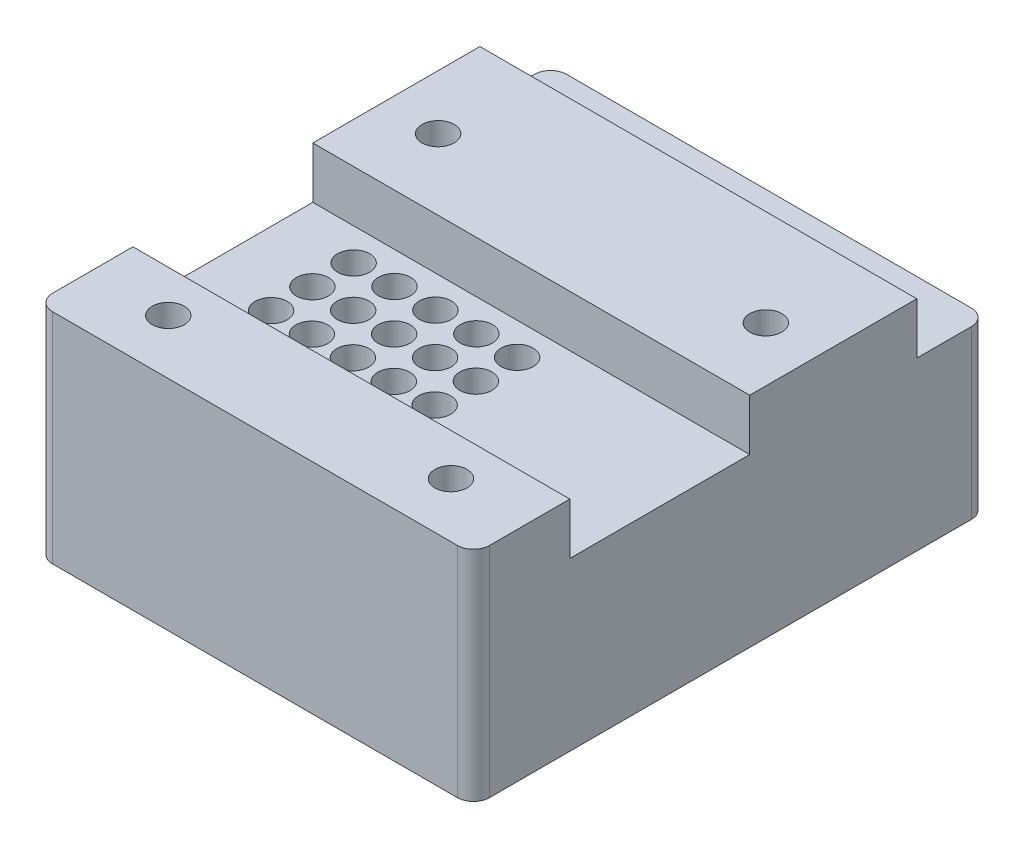
from build123d import *

# Parameters (mm, degrees)
SKETCH1_W            = 68
SKETCH1_H            = 70
BOSS_EXTRUDE2_DEPTH  = 4
SKETCH2_W            = 13.5
SKETCH2_H            = 5
BOSS_EXTRUDE4_DEPTH  = 22
SKETCH3_R            = 2
CUT_EXTRUDE1_DEPTH   = 10
SKETCH4_W            = 5
SKETCH4_H            = 25.69
BOSS_EXTRUDE5_DEPTH  = 15
SKETCH5_R            = 1.3
CUT_EXTRUDE2_DEPTH   = 6
SKETCH6_W            = 68
SKETCH6_H            = 4
BOSS_EXTRUDE6_DEPTH  = 10
BOSS_EXTRUDE7_DEPTH  = 22
SKETCH8_W            = 3
SKETCH8_H            = 26
BOSS_EXTRUDE8_DEPTH  = 22
BOSS_EXTRUDE9_DEPTH  = 22
SKETCH12_W           = 3
SKETCH12_H           = 1
CUT_EXTRUDE5_DEPTH   = 7
SKETCH13_W           = 68
SKETCH13_H           = 26
SKETCH13_H_2         = 15
BOSS_EXTRUDE12_DEPTH = 8
SKETCH19_W           = 6
SKETCH19_H           = 61
CUT_EXTRUDE8_DEPTH   = 22
SKETCH20_W           = 3
SKETCH20_H           = 3
BOSS_EXTRUDE13_DEPTH = 22
SKETCH21_R           = 2.5
CUT_EXTRUDE9_DEPTH   = 22
SKETCH22_R           = 5.004310541
SKETCH22_R_2         = 5.00398022
SKETCH22_R_3         = 4.995044229
SKETCH22_R_4         = 4.998284189
CUT_EXTRUDE10_DEPTH  = 6
SKETCH24_W           = 3
SKETCH24_H           = 3
BOSS_EXTRUDE14_DEPTH = 22
SKETCH26_R           = 1.2
CUT_EXTRUDE11_DEPTH  = 5
SKETCH27_R           = 2.5
CUT_EXTRUDE13_DEPTH  = 10
FILLET2_R            = 2.5


with BuildPart() as part:
    # Sketch1 → Boss-Extrude2 (new body)
    with BuildSketch(Plane(origin=(0, 0, 0), x_dir=(1, 0, 0), z_dir=(0, 1, 0))):
        with Locations((34, -35)):
            Rectangle(SKETCH1_W, SKETCH1_H)
    extrude(amount=BOSS_EXTRUDE2_DEPTH)

    # Sketch2 → Boss-Extrude4 (add)
    with BuildSketch(Plane(origin=(0, 0, 0), x_dir=(-1, 0, 0), z_dir=(0, -1, 0))):
        with Locations((-6.75, -13.5)):
            Rectangle(SKETCH2_W, SKETCH2_H)
        with Locations((-61.25, -13.5)):
            Rectangle(SKETCH2_W, SKETCH2_H)
    extrude(amount=BOSS_EXTRUDE4_DEPTH)

    # Sketch3 → Cut-Extrude1 (cut)
    with BuildSketch(Plane(origin=(0, 0, 11), x_dir=(-1, 0, 0), z_dir=(0, 0, -1))):
        with Locations((-59.07, -14.83)):
            Circle(SKETCH3_R)
        with Locations((-59.07, -4.71)):
            Circle(SKETCH3_R)
        with Locations((-8.93, -14.83)):
            Circle(SKETCH3_R)
        with Locations((-8.93, -4.71)):
            Circle(SKETCH3_R)
    extrude(amount=-CUT_EXTRUDE1_DEPTH, mode=Mode.SUBTRACT)

    # Sketch4 → Boss-Extrude5 (add)
    with BuildSketch(Plane(origin=(0, 0, 0), x_dir=(-1, 0, 0), z_dir=(0, -1, 0))):
        with Locations((-2.5, -54.845)):
            Rectangle(SKETCH4_W, SKETCH4_H)
        with Locations((-45.65, -54.845)):
            Rectangle(SKETCH4_W, SKETCH4_H)
    extrude(amount=BOSS_EXTRUDE5_DEPTH)

    # Sketch5 → Cut-Extrude2 (cut)
    with BuildSketch(Plane(origin=(0, -15, 0), x_dir=(-1, 0, 0), z_dir=(0, -1, 0))):
        with Locations((-2.3, -65.24)):
            Circle(SKETCH5_R)
        with Locations((-2.3, -44.45)):
            Circle(SKETCH5_R)
        with Locations((-45.85, -65.24)):
            Circle(SKETCH5_R)
        with Locations((-45.85, -44.45)):
            Circle(SKETCH5_R)
    extrude(amount=-CUT_EXTRUDE2_DEPTH, mode=Mode.SUBTRACT)

    # Sketch6 → Boss-Extrude6 (add)
    with BuildSketch(Plane.XY.offset(70)):
        with Locations((34, 2)):
            Rectangle(SKETCH6_W, SKETCH6_H)
    extrude(amount=BOSS_EXTRUDE6_DEPTH)

    # Sketch7 → Boss-Extrude7 (add)
    with BuildSketch(Plane(origin=(0, 0, 0), x_dir=(-1, 0, 0), z_dir=(0, -1, 0))):
        Polygon((0, -80), (0, -67.69), (-3, -67.69), (-3, -77), (-59, -77), (-59, -16), (-68, -16), (-68, -80), align=None)
    extrude(amount=BOSS_EXTRUDE7_DEPTH)

    # Sketch8 → Boss-Extrude8 (add)
    with BuildSketch(Plane(origin=(0, 0, 0), x_dir=(-1, 0, 0), z_dir=(0, -1, 0))):
        with Locations((-1.5, -29)):
            Rectangle(SKETCH8_W, SKETCH8_H)
    extrude(amount=BOSS_EXTRUDE8_DEPTH)

    # Sketch9 → Boss-Extrude9 (add)
    with BuildSketch(Plane.XZ):
        Polygon((68, 11), (68, 0), (65, 0), (65, 3), (65, 11), align=None)
        Polygon((0, 11), (0, 0), (3, 0), (3, 3), (3, 11), align=None)
    extrude(amount=BOSS_EXTRUDE9_DEPTH)

    # Sketch12 → Cut-Extrude5 (cut)
    with BuildSketch(Plane(origin=(0, -22, 0), x_dir=(-1, 0, 0), z_dir=(0, -1, 0))):
        with Locations((-1.5, -41.5)):
            Rectangle(SKETCH12_W, SKETCH12_H)
        with Locations((-1.5, -68.19)):
            Rectangle(SKETCH12_W, SKETCH12_H)
    extrude(amount=-CUT_EXTRUDE5_DEPTH, mode=Mode.SUBTRACT)

    # Sketch13 → Boss-Extrude12 (add)
    with BuildSketch(Plane(origin=(0, 4, 0), x_dir=(1, 0, 0), z_dir=(0, 1, 0))):
        with Locations((34, -24)):
            Rectangle(SKETCH13_W, SKETCH13_H)
        with Locations((34, -72.5)):
            Rectangle(SKETCH13_W, SKETCH13_H_2)
    extrude(amount=BOSS_EXTRUDE12_DEPTH)

    # Sketch19 → Cut-Extrude8 (cut)
    with BuildSketch(Plane(origin=(0, -22, 0), x_dir=(-1, 0, 0), z_dir=(0, -1, 0))):
        with Locations((-62, -46.5)):
            Rectangle(SKETCH19_W, SKETCH19_H)
    extrude(amount=-CUT_EXTRUDE8_DEPTH, mode=Mode.SUBTRACT)

    # Sketch20 → Boss-Extrude13 (add)
    with BuildSketch(Plane.XZ):
        with Locations((4.5, 17.5)):
            Rectangle(SKETCH20_W, SKETCH20_H)
        with Locations((63.5, 17.5)):
            Rectangle(SKETCH20_W, SKETCH20_H)
    extrude(amount=BOSS_EXTRUDE13_DEPTH)

    # Sketch21 → Cut-Extrude9 (cut)
    with BuildSketch(Plane(origin=(0, 0, 0), x_dir=(-1, 0, 0), z_dir=(0, -1, 0))):
        with Locations((-8.5, -26)):
            Circle(SKETCH21_R)
        with Locations((-12, -71.5)):
            Circle(SKETCH21_R)
        with Locations((-56, -71.5)):
            Circle(SKETCH21_R)
        with Locations((-59.5, -26)):
            Circle(SKETCH21_R)
    extrude(amount=-CUT_EXTRUDE9_DEPTH, mode=Mode.SUBTRACT)

    # Sketch22 → Cut-Extrude10 (cut)
    with BuildSketch(Plane(origin=(0, 0, 0), x_dir=(-1, 0, 0), z_dir=(0, -1, 0))):
        with Locations((-12, -71.5)):
            Circle(SKETCH22_R)
        with Locations((-8.5, -26)):
            Circle(SKETCH22_R_2)
        with Locations((-59.5, -26)):
            Circle(SKETCH22_R_3)
        with Locations((-56, -71.5)):
            Circle(SKETCH22_R_4)
    extrude(amount=-CUT_EXTRUDE10_DEPTH, mode=Mode.SUBTRACT)

    # Sketch24 → Boss-Extrude14 (add)
    with BuildSketch(Plane(origin=(0, 0, 0), x_dir=(-1, 0, 0), z_dir=(0, -1, 0))):
        with Locations((-4.5, -75.5)):
            Rectangle(SKETCH24_W, SKETCH24_H)
        with Locations((-63.5, -75.5)):
            Rectangle(SKETCH24_W, SKETCH24_H)
    extrude(amount=BOSS_EXTRUDE14_DEPTH)

    # Sketch26 → Cut-Extrude11 (cut)
    with BuildSketch(Plane(origin=(0, -22, 0), x_dir=(-1, 0, 0), z_dir=(0, -1, 0))):
        with Locations((-65, -77)):
            Circle(SKETCH26_R)
        with Locations((-3, -77)):
            Circle(SKETCH26_R)
        with Locations((-65, -16)):
            Circle(SKETCH26_R)
        with Locations((-3, -16)):
            Circle(SKETCH26_R)
    extrude(amount=-CUT_EXTRUDE11_DEPTH, mode=Mode.SUBTRACT)

    # Sketch27 → Cut-Extrude13 (cut)
    with BuildSketch(Plane(origin=(0, 0, 0), x_dir=(-1, 0, 0), z_dir=(0, -1, 0))):
        with Locations((-36.8, -42)):
            Circle(SKETCH27_R)
        with Locations((-30.45, -42)):
            Circle(SKETCH27_R)
        with Locations((-24.075, -42)):
            Circle(SKETCH27_R)
        with Locations((-17.7, -42)):
            Circle(SKETCH27_R)
        with Locations((-11.35, -42)):
            Circle(SKETCH27_R)
        with Locations((-11.35, -48.4225)):
            Circle(SKETCH27_R)
        with Locations((-17.7, -48.4225)):
            Circle(SKETCH27_R)
        with Locations((-24.075, -48.4225)):
            Circle(SKETCH27_R)
        with Locations((-30.45, -48.4225)):
            Circle(SKETCH27_R)
        with Locations((-36.8, -48.4225)):
            Circle(SKETCH27_R)
        with Locations((-36.8, -54.845)):
            Circle(SKETCH27_R)
        with Locations((-36.8, -61.2675)):
            Circle(SKETCH27_R)
        with Locations((-30.45, -54.845)):
            Circle(SKETCH27_R)
        with Locations((-30.45, -61.2675)):
            Circle(SKETCH27_R)
        with Locations((-24.075, -54.845)):
            Circle(SKETCH27_R)
        with Locations((-24.075, -61.2675)):
            Circle(SKETCH27_R)
        with Locations((-17.7, -54.845)):
            Circle(SKETCH27_R)
        with Locations((-17.7, -61.2675)):
            Circle(SKETCH27_R)
        with Locations((-11.35, -54.845)):
            Circle(SKETCH27_R)
        with Locations((-11.35, -61.2675)):
            Circle(SKETCH27_R)
    extrude(amount=-CUT_EXTRUDE13_DEPTH, mode=Mode.SUBTRACT)

    # Fillet2
    fillet2_edges = [part.edges().sort_by_distance(p)[0] for p in [
        (0, -5, 80),
        (68, -5, 80),
        (0, -9, 0),
        (68, -9, 0),
    ]]
    fillet(fillet2_edges, radius=FILLET2_R)


solid = part.part
